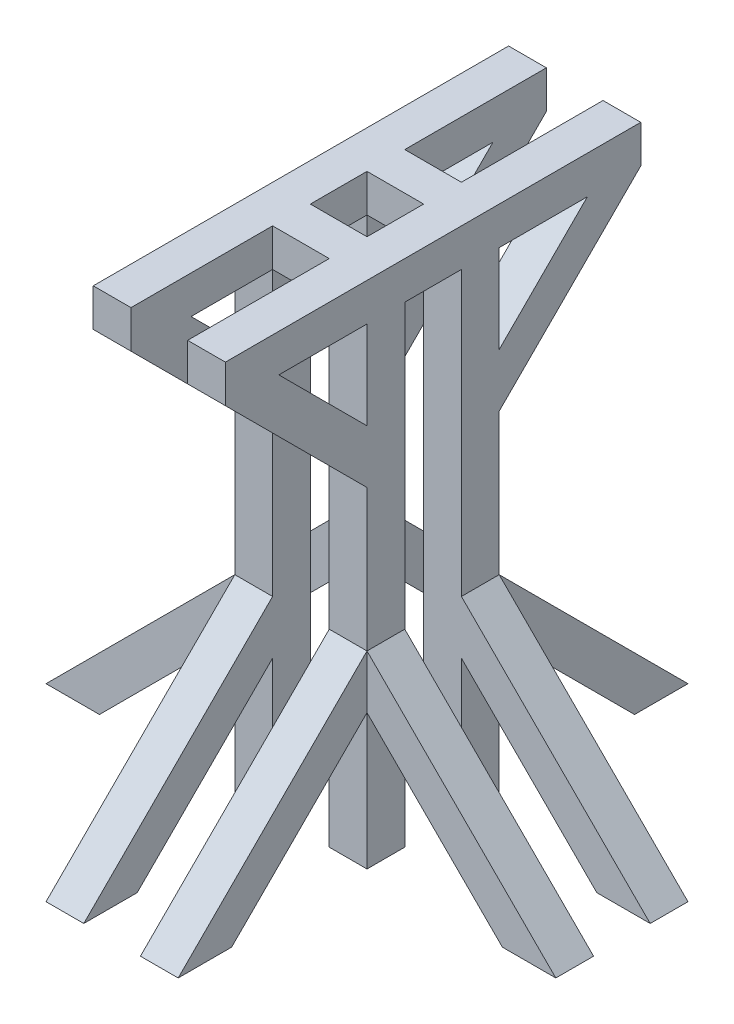
from build123d import *

# Parameters (mm, degrees)
SKETCH_1_W             = 40
SKETCH_1_H             = 40
EXTRUDE_1_DEPTH        = 500
EXTRUDE_1_2_DEPTH      = 500
EXTRUDE_1_3_DEPTH      = 500
EXTRUDE_1_4_DEPTH      = 500
SKETCH_3_W             = 40
SKETCH_3_H             = 440
EXTRUDE_2_DEPTH        = 40
SKETCH_4_W             = 40
SKETCH_4_H             = 440
EXTRUDE_3_DEPTH        = 40
SKETCH_5_W             = 40
SKETCH_5_H             = 40
EXTRUDE_4_DEPTH        = 100
EXTRUDE_5_DEPTH        = 40
EXTRUDE_6_DEPTH        = 40
EXTRUDE_7_DEPTH        = 40
PATTERN_LINEAR_1_COUNT = 2
PATTERN_LINEAR_1_PITCH = 100
EXTRUDE_8_DEPTH        = 40
EXTRUDE_9_DEPTH        = 40


with BuildPart() as part:
    # 草图1 → 凸台-拉伸1 (new body)
    with BuildSketch(Plane(origin=(0, 0, 0), x_dir=(1, 0, 0), z_dir=(0, 1, 0))):
        with Locations((20, -20)):
            Rectangle(SKETCH_1_W, SKETCH_1_H)
    extrude(amount=EXTRUDE_1_DEPTH)



with BuildPart() as body_2:
    # 草图1 → Extrude 1 2 (new body)
    with BuildSketch(Plane(origin=(0, 0, 0), x_dir=(1, 0, 0), z_dir=(0, 1, 0))):
        with Locations((120, -20)):
            Rectangle(SKETCH_1_W, SKETCH_1_H)
    extrude(amount=EXTRUDE_1_2_DEPTH)



with BuildPart() as body_3:
    # 草图1 → Extrude 1 3 (new body)
    with BuildSketch(Plane(origin=(0, 0, 0), x_dir=(1, 0, 0), z_dir=(0, 1, 0))):
        with Locations((20, -120)):
            Rectangle(SKETCH_1_W, SKETCH_1_H)
    extrude(amount=EXTRUDE_1_3_DEPTH)


with BuildPart() as body_4:
    # 草图1 → Extrude 1 4 (new body)
    with BuildSketch(Plane(origin=(0, 0, 0), x_dir=(1, 0, 0), z_dir=(0, 1, 0))):
        with Locations((120, -120)):
            Rectangle(SKETCH_1_W, SKETCH_1_H)
    extrude(amount=EXTRUDE_1_4_DEPTH)


with BuildPart() as part_1:
    add(part.part)

    add(body_3.part)  # 凸台-拉伸2 merges body 3
    # 草图3 → 凸台-拉伸2 (add)
    with BuildSketch(Plane(origin=(0, 500, 0), x_dir=(1, 0, 0), z_dir=(0, 1, 0))):
        with Locations((20, -70)):
            Rectangle(SKETCH_3_W, SKETCH_3_H)
    extrude(amount=EXTRUDE_2_DEPTH)



with BuildPart() as body_2_1:
    add(body_2.part)

    add(body_4.part)  # 凸台-拉伸3 merges body 4
    # 草图4 → 凸台-拉伸3 (add)
    with BuildSketch(Plane(origin=(0, 500, 0), x_dir=(1, 0, 0), z_dir=(0, 1, 0))):
        with Locations((120, -70)):
            Rectangle(SKETCH_4_W, SKETCH_4_H)
    extrude(amount=EXTRUDE_3_DEPTH)


with BuildPart() as part_2:
    add(part_1.part)

    add(body_2_1.part)  # 凸台-拉伸4 merges body 2
    # 草图5 → 凸台-拉伸4 (add)
    with BuildSketch(Plane(origin=(40, 0, 0), x_dir=(0, 0, -1), z_dir=(1, 0, 0))):
        with Locations((-120, 520)):
            Rectangle(SKETCH_5_W, SKETCH_5_H)
        with Locations((-20, 520)):
            Rectangle(SKETCH_5_W, SKETCH_5_H)
    extrude(amount=EXTRUDE_4_DEPTH)

    # 草图6 → 凸台-拉伸5 (add)
    with BuildSketch(Plane(origin=(140, 0, 0), x_dir=(0, 0, -1), z_dir=(1, 0, 0))):
        Polygon((-290, 500), (-140, 350), (-140, 406.568542495), (-233.431457505, 500), align=None)
        Polygon((150, 500), (0, 350), (0, 406.568542495), (93.431457505, 500), align=None)
    extrude(amount=-EXTRUDE_5_DEPTH)

    # 草图7 → 凸台-拉伸6 (add)
    with BuildSketch(Plane.ZY):
        Polygon((-150, 500), (0, 350), (0, 406.568542495), (-93.431457505, 500), align=None)
        Polygon((290, 500), (140, 350), (140, 413.639610307), (226.360389693, 500), align=None)
    extrude(amount=-EXTRUDE_6_DEPTH)

    # 草图8 → 凸台-拉伸7 (add)
    with BuildSketch(Plane.ZY):
        Polygon((0, 143.431457505), (0, 200), (-200, 0), (-143.431457505, 0), align=None)
        Polygon((140, 143.431457505), (283.431457505, 0), (340, 0), (140, 200), align=None)
    extrude_7 = extrude(amount=-EXTRUDE_7_DEPTH)

    # 阵列(线性)1: 凸台-拉伸7 ×2
    with Locations(*[(i * PATTERN_LINEAR_1_PITCH, 0, 0) for i in range(1, PATTERN_LINEAR_1_COUNT)]):
        add(extrude_7)

    # 草图9 → 凸台-拉伸8 (add)
    with BuildSketch(Plane(origin=(0, 0, 0), x_dir=(-1, 0, 0), z_dir=(0, 0, -1))):
        Polygon((-340, 0), (-283.431457505, 0), (-140, 143.431457505), (-140, 200), align=None)
        Polygon((200, 0), (0, 200), (0, 143.431457505), (143.431457505, 0), align=None)
    extrude(amount=-EXTRUDE_8_DEPTH)

    # 草图10 → 凸台-拉伸9 (add)
    with BuildSketch(Plane.XY.offset(140)):
        Polygon((0, 143.431457505), (0, 200), (-200, 0), (-143.431457505, 0), align=None)
        Polygon((140, 143.431457505), (283.431457505, 0), (340, 0), (140, 200), align=None)
    extrude(amount=-EXTRUDE_9_DEPTH)


solid = part_2.part
